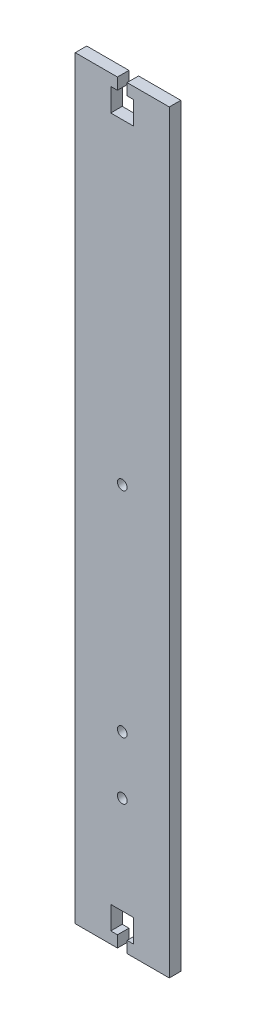
from build123d import *

# Parameters (mm, degrees)
SKETCH1_W           = 40.89
SKETCH1_H           = 328
BOSS_EXTRUDE1_DEPTH = 5
SKETCH2_R           = 2.1
CUT_EXTRUDE1_DEPTH  = 10
CUT_EXTRUDE2_DEPTH  = 10
SKETCH4_R           = 2.1
CUT_EXTRUDE3_DEPTH  = 5
SKETCH5_R           = 2.1
CUT_EXTRUDE4_DEPTH  = 5


with BuildPart() as part:
    # Sketch1 → Boss-Extrude1 (new body)
    with BuildSketch(Plane.XY):
        Rectangle(SKETCH1_W, SKETCH1_H)
    extrude(amount=BOSS_EXTRUDE1_DEPTH)

    # Sketch2 → Cut-Extrude1 (cut)
    with BuildSketch(Plane.XY.offset(5)):
        with Locations((0, -81.5)):
            Circle(SKETCH2_R)
    extrude(amount=-CUT_EXTRUDE1_DEPTH, mode=Mode.SUBTRACT)

    # Sketch3 → Cut-Extrude2 (cut)
    with BuildSketch(Plane.XY.offset(5)):
        Polygon((-2.1, -164), (-2.1, -159), (-5, -159), (-5, -149), (5, -149), (5, -159), (2.1, -159), (2.1, -164), align=None)
        Polygon((2.1, 164), (2.1, 159), (5, 159), (5, 149), (-5, 149), (-5, 159), (-2.1, 159), (-2.1, 164), align=None)
    extrude(amount=-CUT_EXTRUDE2_DEPTH, mode=Mode.SUBTRACT)

    # Sketch4 → Cut-Extrude3 (cut)
    with BuildSketch(Plane.XY.offset(5)):
        with Locations((0, -106.5)):
            Circle(SKETCH4_R)
    extrude(amount=-CUT_EXTRUDE3_DEPTH, mode=Mode.SUBTRACT)

    # Sketch5 → Cut-Extrude4 (cut)
    with BuildSketch(Plane.XY.offset(5)):
        with Locations((0, 11.5)):
            Circle(SKETCH5_R)
    extrude(amount=-CUT_EXTRUDE4_DEPTH, mode=Mode.SUBTRACT)


solid = part.part
